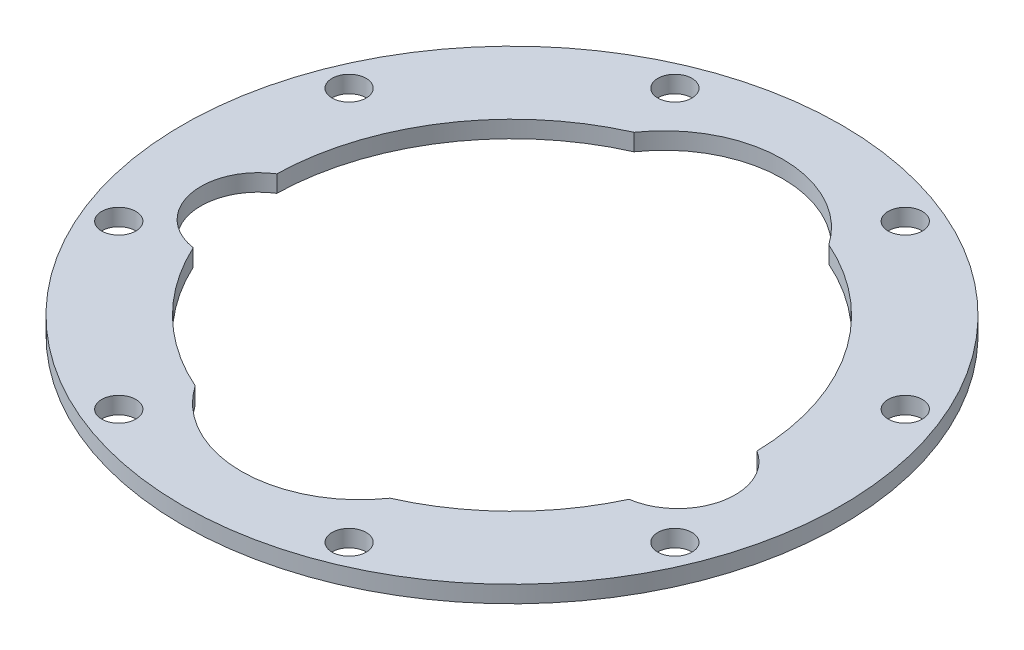
from build123d import *

# Parameters (mm, degrees)
SKETCH2_R           = 97.45
SKETCH2_R_2         = 5.05
BOSS_EXTRUDE1_DEPTH = 5


with BuildPart() as part:
    # Sketch2 → Boss-Extrude1 (new body)
    with BuildSketch(Plane(origin=(0, 0, 0), x_dir=(1, 0, 0), z_dir=(0, 1, 0))):
        Circle(SKETCH2_R)
        with Locations((-34.05882548, -82.225278394)):
            Circle(SKETCH2_R_2, mode=Mode.SUBTRACT)
        with Locations((-82.225278394, -34.05882548)):
            Circle(SKETCH2_R_2, mode=Mode.SUBTRACT)
        with Locations((34.05882548, -82.225278394)):
            Circle(SKETCH2_R_2, mode=Mode.SUBTRACT)
        with Locations((82.225278394, -34.05882548)):
            Circle(SKETCH2_R_2, mode=Mode.SUBTRACT)
        with Locations((-82.225278394, 34.05882548)):
            Circle(SKETCH2_R_2, mode=Mode.SUBTRACT)
        with Locations((-34.05882548, 82.225278394)):
            Circle(SKETCH2_R_2, mode=Mode.SUBTRACT)
        with BuildLine():
            ThreePointArc((-64.431819773, -29.825167238), (-78.638188145, -16.488652353), (-70.985573699, 1.431197639))
            ThreePointArc((-70.985573699, 1.431197639), (-59.126750062, 39.306836901), (-28.79218644, 64.9))
            ThreePointArc((-28.79218644, 64.9), (0, 80), (28.79218644, 64.9))
            ThreePointArc((28.79218644, 64.9), (59.126750062, 39.306836901), (70.985573699, 1.431197639))
            ThreePointArc((70.985573699, 1.431197639), (78.638188145, -16.488652353), (64.431819773, -29.825167238))
            ThreePointArc((64.431819773, -29.825167238), (49.802006053, -50.603954323), (28.79218644, -64.9))
            ThreePointArc((28.79218644, -64.9), (0, -80), (-28.79218644, -64.9))
            ThreePointArc((-28.79218644, -64.9), (-49.802006053, -50.603954323), (-64.431819773, -29.825167238))
        make_face(mode=Mode.SUBTRACT)
        with Locations((82.225278394, 34.05882548)):
            Circle(SKETCH2_R_2, mode=Mode.SUBTRACT)
        with Locations((34.05882548, 82.225278394)):
            Circle(SKETCH2_R_2, mode=Mode.SUBTRACT)
    extrude(amount=BOSS_EXTRUDE1_DEPTH)


solid = part.part
